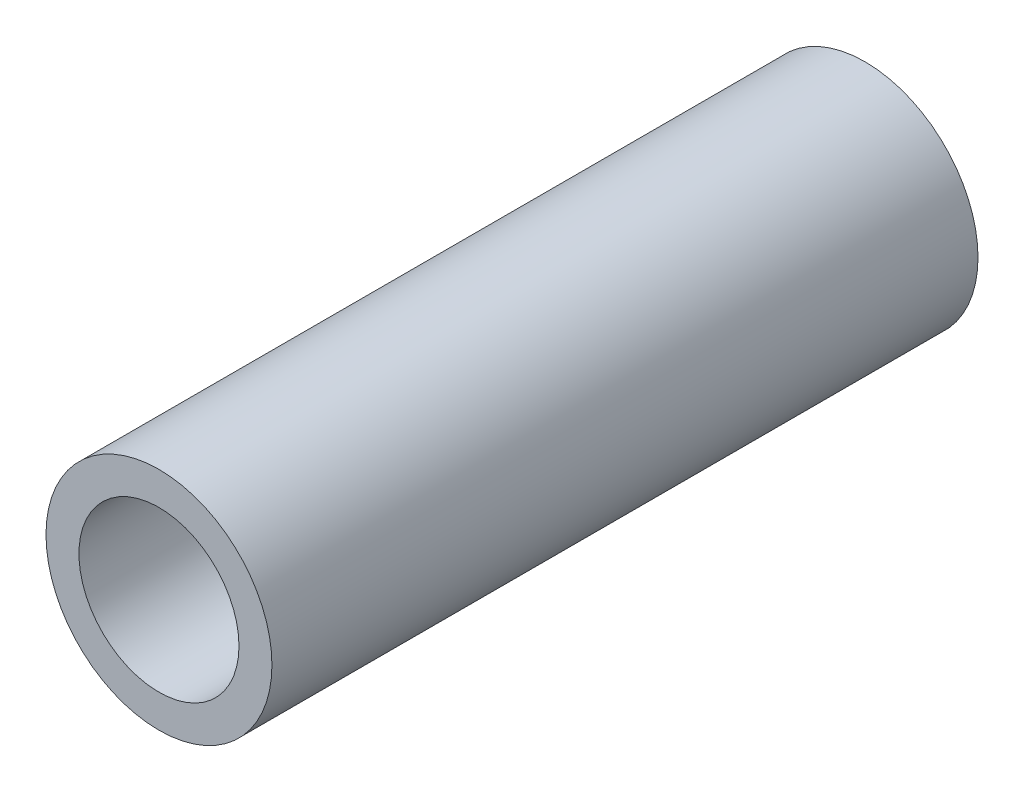
from build123d import *

# Parameters (mm, degrees)
SKETCH1_R           = 12
SKETCH1_R_2         = 8.5
BOSS_EXTRUDE1_DEPTH = 37.5


with BuildPart() as part:
    # Sketch1 → Boss-Extrude1 (new body, symmetric)
    with BuildSketch(Plane.XY):
        Circle(SKETCH1_R)
        Circle(SKETCH1_R_2, mode=Mode.SUBTRACT)
    extrude(amount=BOSS_EXTRUDE1_DEPTH, both=True)


solid = part.part
